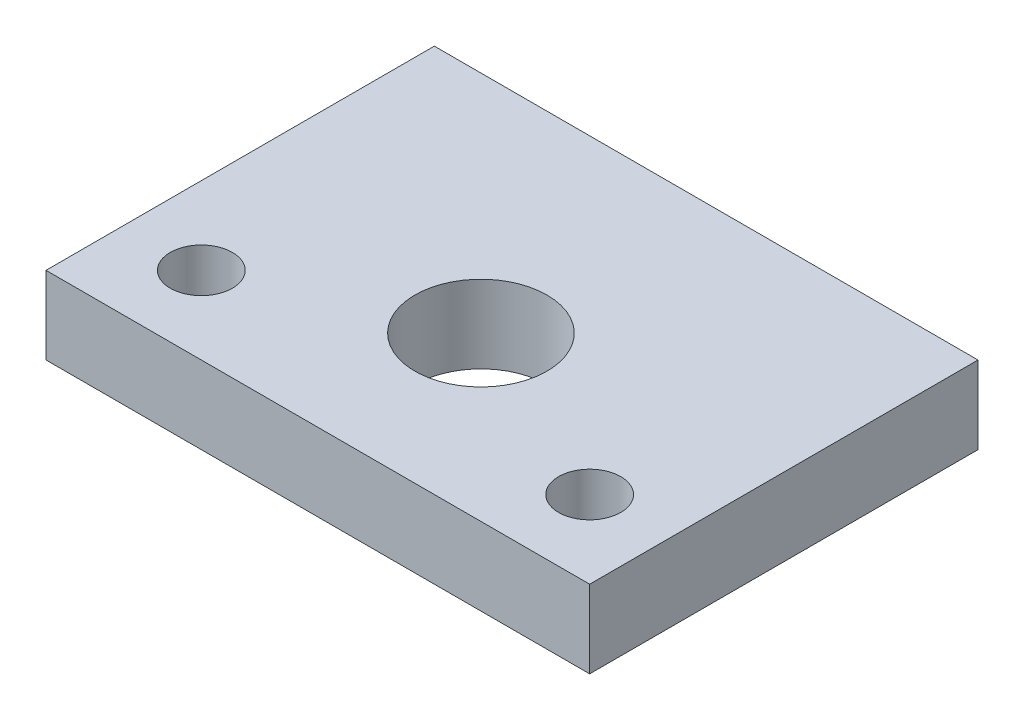
from build123d import *

# Parameters (mm, degrees)
SKETCH2_W           = 70
SKETCH2_H           = 50
BOSS_EXTRUDE1_DEPTH = 10
SKETCH3_R           = 4
CUT_EXTRUDE1_DEPTH  = 11
SKETCH5_R           = 8.5
CUT_EXTRUDE3_DEPTH  = 11


with BuildPart() as part:
    # Sketch2 → Boss-Extrude1 (new body)
    with BuildSketch(Plane(origin=(0, 0, 0), x_dir=(1, 0, 0), z_dir=(0, 1, 0))):
        Rectangle(SKETCH2_W, SKETCH2_H)
    extrude(amount=BOSS_EXTRUDE1_DEPTH)

    # Sketch3 → Cut-Extrude1 (cut, through all)
    with BuildSketch(Plane.XZ):
        with Locations((-25, 15)):
            Circle(SKETCH3_R)
        with Locations((25, 15)):
            Circle(SKETCH3_R)
    extrude(amount=-CUT_EXTRUDE1_DEPTH, mode=Mode.SUBTRACT)

    # Sketch5 → Cut-Extrude3 (cut, through all)
    with BuildSketch(Plane.XZ):
        with Locations((0, 4)):
            Circle(SKETCH5_R)
    extrude(amount=-CUT_EXTRUDE3_DEPTH, mode=Mode.SUBTRACT)


solid = part.part
